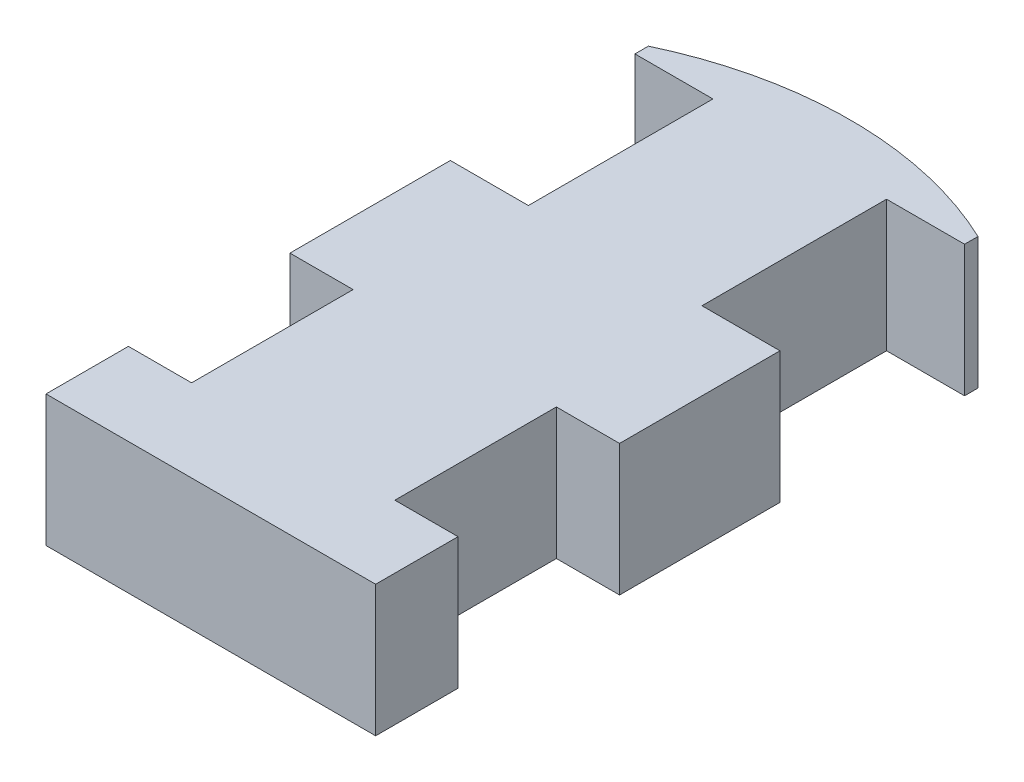
from build123d import *

# Parameters (mm, degrees)
BOSS_EXTRUDE1_DEPTH = 60.706


with BuildPart() as part:
    # Sketch2 → Boss-Extrude1 (new body)
    with BuildSketch(Plane(origin=(0, 0, 0), x_dir=(1, 0, 0), z_dir=(0, 1, 0))):
        with BuildLine():
            Line((-76.2, -147.828), (76.2, -147.828))
            Line((76.2, -147.828), (76.2, -109.728))
            Line((76.2, -109.728), (46.99, -109.728))
            Line((46.99, -109.728), (46.99, -35.052))
            Line((46.99, -35.052), (76.2, -35.052))
            Line((76.2, -35.052), (76.2, 39.116))
            Line((76.2, 39.116), (40.132, 39.116))
            Line((40.132, 39.116), (40.132, 124.46))
            Line((40.132, 124.46), (76.2, 124.46))
            Line((76.2, 124.46), (76.2, 130.671705137))
            ThreePointArc((76.2, 130.671705137), (0, 147.828), (-76.2, 130.671705137))
            Line((-76.2, 130.671705137), (-76.2, 124.46))
            Line((-76.2, 124.46), (-40.132, 124.46))
            Line((-40.132, 124.46), (-40.132, 39.116))
            Line((-40.132, 39.116), (-76.2, 39.116))
            Line((-76.2, 39.116), (-76.2, -35.052))
            Line((-76.2, -35.052), (-46.99, -35.052))
            Line((-46.99, -35.052), (-46.99, -109.728))
            Line((-46.99, -109.728), (-76.2, -109.728))
            Line((-76.2, -109.728), (-76.2, -147.828))
        make_face()
    extrude(amount=BOSS_EXTRUDE1_DEPTH)


solid = part.part
